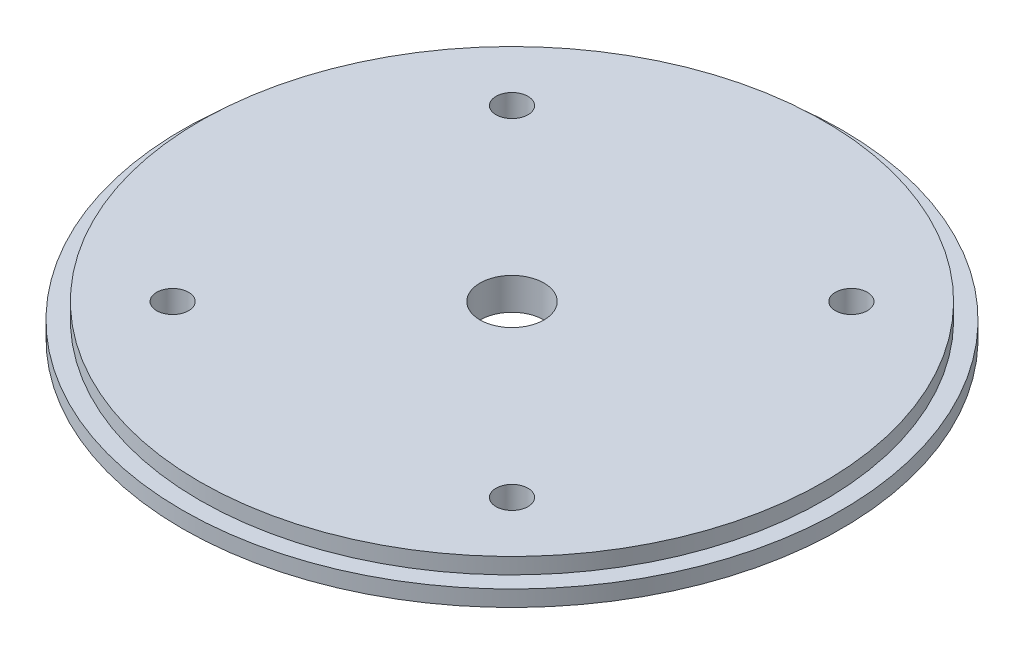
from build123d import *

# Parameters (mm, degrees)
SKETCH2_R                   = 65.405
BOSS_EXTRUDE1_DEPTH         = 6.35
SKETCH4_R                   = 65.405
SKETCH4_R_2                 = 61.976
CUT_EXTRUDE1_DEPTH          = 3.175
F_1_4_0_25_DIAMETER_HOLE1_D = 6.35
F_1_2_0_5_DIAMETER_HOLE1_D  = 12.7
SKETCH9_R                   = 6.0325
CUT_EXTRUDE2_DEPTH          = 1.5875


with BuildPart() as part:
    # Sketch2 → Boss-Extrude1 (new body)
    with BuildSketch(Plane(origin=(0, 0, 0), x_dir=(1, 0, 0), z_dir=(0, 1, 0))):
        Circle(SKETCH2_R)
    extrude(amount=BOSS_EXTRUDE1_DEPTH)

    # Sketch4 → Cut-Extrude1 (cut)
    with BuildSketch(Plane(origin=(0, 6.35, 0), x_dir=(1, 0, 0), z_dir=(0, 1, 0))):
        Circle(SKETCH4_R)
        Circle(SKETCH4_R_2, mode=Mode.SUBTRACT)
    extrude(amount=-CUT_EXTRUDE1_DEPTH, mode=Mode.SUBTRACT)

    # 1/4 (0.25) Diameter Hole1 (through all)
    with Locations(Plane(origin=(0, 6.35, 0), x_dir=(1, 0, 0), z_dir=(0, 1, 0))):
        with Locations((-33.675960454, 33.675960454), (-33.675960454, -33.675960454), (33.675960454, 33.675960454), (33.675960454, -33.675960454)):
            Hole(F_1_4_0_25_DIAMETER_HOLE1_D / 2)

    # 1/2 (0.5) Diameter Hole1 (through all)
    with Locations(Plane(origin=(0, 6.35, 0), x_dir=(1, 0, 0), z_dir=(0, 1, 0))):
        with Locations((0, 0)):
            Hole(F_1_2_0_5_DIAMETER_HOLE1_D / 2)

    # Sketch9 → Cut-Extrude2 (cut)
    with BuildSketch(Plane.XZ):
        with Locations((-33.675960454, 33.675960454)):
            Circle(SKETCH9_R)
        with Locations((33.675960454, 33.675960454)):
            Circle(SKETCH9_R)
        with Locations((33.675960454, -33.675960454)):
            Circle(SKETCH9_R)
        with Locations((-33.675960454, -33.675960454)):
            Circle(SKETCH9_R)
    extrude(amount=-CUT_EXTRUDE2_DEPTH, mode=Mode.SUBTRACT)


solid = part.part
